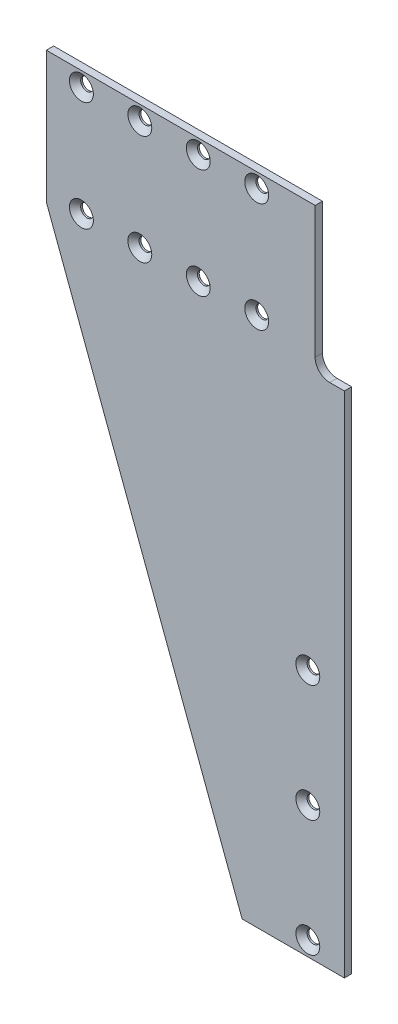
from build123d import *

# Parameters (mm, degrees)
BOSS_EXTRUDE1_DEPTH                       = 3.175
CSK_FOR_0_FLAT_HEAD_MACHINE_SCREW_2_COUNT = 2
CSK_FOR_0_FLAT_HEAD_MACHINE_SCREW_2_PITCH = 47.625
LPATTERN1_COUNT                           = 4
LPATTERN1_PITCH                           = 25.4
LPATTERN2_COUNT                           = 3
LPATTERN2_PITCH                           = 50.8


with BuildPart() as part:
    # Sketch1 → Boss-Extrude1 (new body)
    with BuildSketch(Plane.XY):
        with BuildLine():
            Line((0, 0), (0, 220.98))
            Line((0, 220.98), (-6.35, 220.98))
            ThreePointArc((-6.35, 220.98), (-10.840128061, 222.839871939), (-12.7, 227.33))
            Line((-12.7, 227.33), (-12.7, 284.48))
            Line((-12.7, 284.48), (-129.54, 284.48))
            Line((-129.54, 284.48), (-129.54, 227.33))
            Line((-129.54, 227.33), (-44.45, 0))
            Line((-44.45, 0), (0, 0))
        make_face()
    extrude(amount=-BOSS_EXTRUDE1_DEPTH)

    # Sketch3 → CSK for _0 Flat Head Machine Screw _100 (revolve, cut)
    with BuildSketch(Plane(origin=(-114.3, 278.13, 0), x_dir=(0, -1, 0), z_dir=(1, 0, 0))):
        Polygon((0, 0), (0, 3.175), (2.7559, 3.175), (2.7559, 2.4384), (5.1943, 0), align=None)
    csk_for_0_flat_head_machine_screw_100 = revolve(axis=Axis((-114.3, 278.13, 6.35), (0, 0, -1)), mode=Mode.SUBTRACT)

    # CSK for _0 Flat Head Machine Screw _ 2: CSK for _0 Flat Head Machine Screw _100 ×2
    with Locations(*[(0, -i * CSK_FOR_0_FLAT_HEAD_MACHINE_SCREW_2_PITCH, 0) for i in range(1, CSK_FOR_0_FLAT_HEAD_MACHINE_SCREW_2_COUNT)]):
        add(csk_for_0_flat_head_machine_screw_100, mode=Mode.SUBTRACT)

    # LPattern1: CSK for _0 Flat Head Machine Screw _100 ×4
    with Locations(*[(i * LPATTERN1_PITCH, 0, 0) for i in range(1, LPATTERN1_COUNT)]):
        add(csk_for_0_flat_head_machine_screw_100, mode=Mode.SUBTRACT)

    # LPattern1 copy 1 sketch → LPattern1 copy 1 (revolve, cut)
    with BuildSketch(Plane(origin=(-88.9, 230.505, 0), x_dir=(0, -1, 0), z_dir=(1, 0, 0))):
        Polygon((0, 0), (0, 3.175), (2.7559, 3.175), (2.7559, 2.4384), (5.1943, 0), align=None)
    revolve(axis=Axis((-88.9, 230.505, 6.35), (0, 0, -1)), mode=Mode.SUBTRACT)

    # LPattern1 copy 2 sketch → LPattern1 copy 2 (revolve, cut)
    with BuildSketch(Plane(origin=(-63.5, 230.505, 0), x_dir=(0, -1, 0), z_dir=(1, 0, 0))):
        Polygon((0, 0), (0, 3.175), (2.7559, 3.175), (2.7559, 2.4384), (5.1943, 0), align=None)
    revolve(axis=Axis((-63.5, 230.505, 6.35), (0, 0, -1)), mode=Mode.SUBTRACT)

    # LPattern1 copy 3 sketch → LPattern1 copy 3 (revolve, cut)
    with BuildSketch(Plane(origin=(-38.1, 230.505, 0), x_dir=(0, -1, 0), z_dir=(1, 0, 0))):
        Polygon((0, 0), (0, 3.175), (2.7559, 3.175), (2.7559, 2.4384), (5.1943, 0), align=None)
    revolve(axis=Axis((-38.1, 230.505, 6.35), (0, 0, -1)), mode=Mode.SUBTRACT)

    # Sketch4 → CSK for _0 Flat Head Machine Screw _ 3 (revolve, cut)
    with BuildSketch(Plane(origin=(-15.875, 107.95, 0), x_dir=(0, -1, 0), z_dir=(1, 0, 0))):
        Polygon((0, 0), (0, 3.175), (2.7559, 3.175), (2.7559, 2.4384), (5.1943, 0), align=None)
    csk_for_0_flat_head_machine_screw_3 = revolve(axis=Axis((-15.875, 107.95, 6.35), (0, 0, -1)), mode=Mode.SUBTRACT)

    # LPattern2: CSK for _0 Flat Head Machine Screw _ 3 ×3
    with Locations(*[(0, -i * LPATTERN2_PITCH, 0) for i in range(1, LPATTERN2_COUNT)]):
        add(csk_for_0_flat_head_machine_screw_3, mode=Mode.SUBTRACT)


solid = part.part
